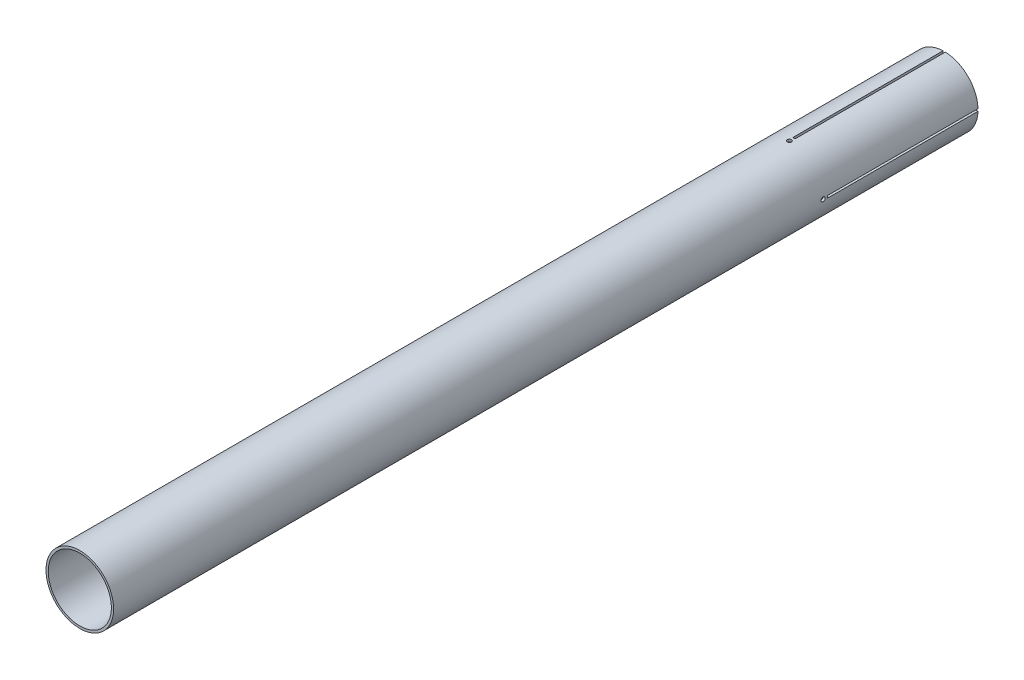
from build123d import *

# Parameters (mm, degrees)
ESQUISSE1_R                            = 45
BOSS_EXTRU_1_DEPTH                     = 1150
ESQUISSE2_R                            = 42
ENL_V_MAT_EXTRU_1_DEPTH                = 1150
ESQUISSE3_W                            = 10
ESQUISSE3_H                            = 3
ENL_V_MAT_EXTRU_2_DEPTH                = 200
R_P_TITION_CIRCULAIRE1_COUNT           = 4
ESQUISSE5_W                            = 2.75
ESQUISSE5_H                            = 90
D_GAGEMENT_M51_AT_2_COUNT              = 2
D_GAGEMENT_M51_AT_2_PITCH              = 214.601725843
R_P_TITION_CIRCULAIRE2_COUNT           = 2
R_P_TITION_CIRCULAIRE2_ANGLE           = 90
R_P_TITION_CIRCULAIRE2_COPY_1_SKETCH_W = 2.75
R_P_TITION_CIRCULAIRE2_COPY_1_SKETCH_H = 90


with BuildPart() as part:
    # Esquisse1 → Boss.-Extru.1 (new body)
    with BuildSketch(Plane.XY):
        Circle(ESQUISSE1_R)
    extrude(amount=BOSS_EXTRU_1_DEPTH)

    # Esquisse2 → Enlèv. mat.-Extru.1 (cut)
    with BuildSketch(Plane(origin=(0, 0, 0), x_dir=(-1, 0, 0), z_dir=(0, 0, -1))):
        Circle(ESQUISSE2_R)
    extrude(amount=-ENL_V_MAT_EXTRU_1_DEPTH, mode=Mode.SUBTRACT)

    # Esquisse3 → Enlèv. mat.-Extru.2 (cut)
    with BuildSketch(Plane.XY):
        with Locations((-45, 0)):
            Rectangle(ESQUISSE3_W, ESQUISSE3_H)
    enl_v_mat_extru_2 = extrude(amount=ENL_V_MAT_EXTRU_2_DEPTH, mode=Mode.SUBTRACT)

    # Répétition circulaire1: Enlèv. mat.-Extru.2 ×4 about axis
    r_p_tition_circulaire1_axis = Axis((0, 0, 0), (0, 0, 1))
    for i in range(1, R_P_TITION_CIRCULAIRE1_COUNT):
        add(enl_v_mat_extru_2.rotate(r_p_tition_circulaire1_axis, i * 360 / R_P_TITION_CIRCULAIRE1_COUNT), mode=Mode.SUBTRACT)

    # Esquisse5 → Dégagement M51 (revolve, cut)
    with BuildSketch(Plane(origin=(-45, 0, 206), x_dir=(0, 0, 1), z_dir=(0, 1, 0))):
        with Locations((1.375, 45)):
            Rectangle(ESQUISSE5_W, ESQUISSE5_H)
    d_gagement_m51 = revolve(axis=Axis((-51.35, 0, 206), (1, 0, 0)), mode=Mode.SUBTRACT)

    # Dégagement M51 at 2: Dégagement M51 ×2
    with Locations(*[Vector(0, -0.280281939, -0.959917723) * (i * D_GAGEMENT_M51_AT_2_PITCH) for i in range(1, D_GAGEMENT_M51_AT_2_COUNT)]):
        add(d_gagement_m51, mode=Mode.SUBTRACT)

    # Répétition circulaire2: Dégagement M51 ×2 about axis
    r_p_tition_circulaire2_axis = Axis((0, 0, 0), (0, 0, 1))
    for i in range(1, R_P_TITION_CIRCULAIRE2_COUNT):
        add(d_gagement_m51.rotate(r_p_tition_circulaire2_axis, i * R_P_TITION_CIRCULAIRE2_ANGLE / (R_P_TITION_CIRCULAIRE2_COUNT - 1)), mode=Mode.SUBTRACT)

    # Répétition circulaire2 copy 1 sketch → Répétition circulaire2 copy 1 (revolve, cut)
    with BuildSketch(Plane(origin=(60.14898781, -45, 0), x_dir=(0, 0, 1), z_dir=(-1, 0, 0))):
        with Locations((1.375, 45)):
            Rectangle(R_P_TITION_CIRCULAIRE2_COPY_1_SKETCH_W, R_P_TITION_CIRCULAIRE2_COPY_1_SKETCH_H)
    revolve(axis=Axis((60.14898781, -51.35, 0), (0, 1, 0)), mode=Mode.SUBTRACT)


solid = part.part
